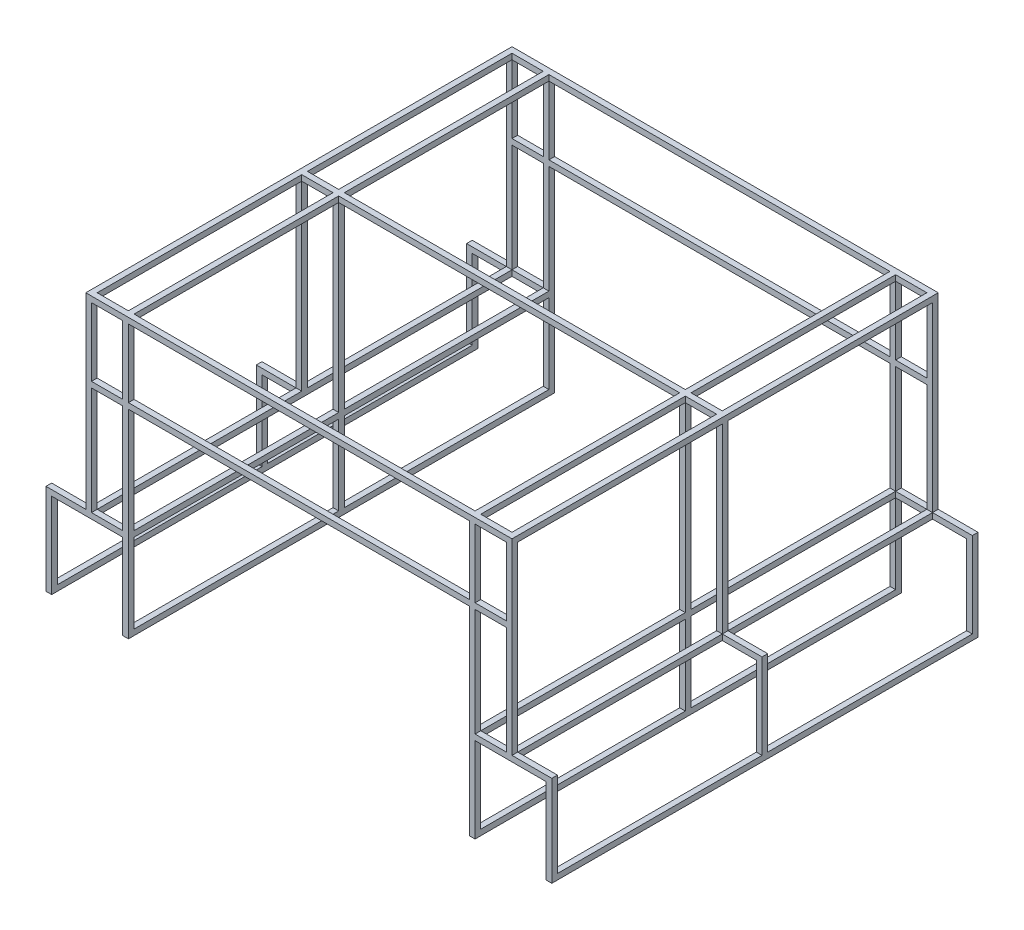
from build123d import *

# Parameters (mm, degrees)
SKETCH1_W                = 150
SKETCH1_H                = 1500
SKETCH1_W_2              = 110
SKETCH1_H_2              = 1460
BOSS_EXTRUDE1_DEPTH      = 20
SKETCH2_W                = 20
SKETCH2_H                = 20
BOSS_EXTRUDE2_DEPTH      = 640
SKETCH3_W                = 150
SKETCH3_H                = 1500
SKETCH3_W_2              = 110
SKETCH3_H_2              = 1460
BOSS_EXTRUDE3_DEPTH      = 20
SKETCH4_W                = 20
SKETCH4_H                = 20
BOSS_EXTRUDE4_DEPTH      = 660
SKETCH5_W                = 20
SKETCH5_H                = 20
BOSS_EXTRUDE5_DEPTH      = 600
BOSS_EXTRUDE5_DEPTH_BACK = 130
SKETCH6_W                = 140
SKETCH6_H                = 20
BOSS_EXTRUDE6_DEPTH      = 20
SKETCH7_W                = 20
SKETCH7_H                = 20
BOSS_EXTRUDE7_DEPTH      = 300
BOSS_EXTRUDE8_START      = -1480
SKETCH8_W                = 20
SKETCH8_H                = 20
BOSS_EXTRUDE8_DEPTH      = 1460


with BuildPart() as part:
    # Sketch1 → Boss-Extrude1 (new body)
    with BuildSketch(Plane(origin=(0, 0, 0), x_dir=(1, 0, 0), z_dir=(0, 1, 0))):
        with Locations((675, 0)):
            Rectangle(SKETCH1_W, SKETCH1_H)
        with Locations((675, 0)):
            Rectangle(SKETCH1_W_2, SKETCH1_H_2, mode=Mode.SUBTRACT)
    extrude(amount=BOSS_EXTRUDE1_DEPTH)

    # Sketch2 → Boss-Extrude2 (add)
    with BuildSketch(Plane(origin=(0, 20, 0), x_dir=(1, 0, 0), z_dir=(0, 1, 0))):
        with Locations((610, 740)):
            Rectangle(SKETCH2_W, SKETCH2_H)
        with Locations((740, 740)):
            Rectangle(SKETCH2_W, SKETCH2_H)
        with Locations((610, -740)):
            Rectangle(SKETCH2_W, SKETCH2_H)
        with Locations((740, -740)):
            Rectangle(SKETCH2_W, SKETCH2_H)
    extrude(amount=BOSS_EXTRUDE2_DEPTH)

    # Sketch3 → Boss-Extrude3 (add)
    with BuildSketch(Plane(origin=(0, 660, 0), x_dir=(1, 0, 0), z_dir=(0, 1, 0))):
        with Locations((675, 0)):
            Rectangle(SKETCH3_W, SKETCH3_H)
        with Locations((675, 0)):
            Rectangle(SKETCH3_W_2, SKETCH3_H_2, mode=Mode.SUBTRACT)
    extrude(amount=BOSS_EXTRUDE3_DEPTH)

    # Sketch4 → Boss-Extrude4 (add)
    with BuildSketch(Plane.XZ):
        with Locations((740, 0)):
            Rectangle(SKETCH4_W, SKETCH4_H)
        with Locations((610, 0)):
            Rectangle(SKETCH4_W, SKETCH4_H)
    extrude(amount=-BOSS_EXTRUDE4_DEPTH)

    # Sketch5 → Boss-Extrude5 (add, two sides)
    with BuildSketch(Plane.ZY.offset(-600)) as boss_extrude5_sk:
        with Locations((-740, 410)):
            Rectangle(SKETCH5_W, SKETCH5_H)
        with Locations((-740, 670)):
            Rectangle(SKETCH5_W, SKETCH5_H)
        with Locations((740, 410)):
            Rectangle(SKETCH5_W, SKETCH5_H)
        with Locations((740, 670)):
            Rectangle(SKETCH5_W, SKETCH5_H)
        with Locations((0, 670)):
            Rectangle(SKETCH5_W, SKETCH5_H)
    extrude(amount=BOSS_EXTRUDE5_DEPTH)
    extrude(boss_extrude5_sk.sketch, amount=-BOSS_EXTRUDE5_DEPTH_BACK)

    # Sketch6 → Boss-Extrude6 (add)
    with BuildSketch(Plane.XZ):
        with Locations((820, 740)):
            Rectangle(SKETCH6_W, SKETCH6_H)
        with Locations((820, 0)):
            Rectangle(SKETCH6_W, SKETCH6_H)
        with Locations((820, -740)):
            Rectangle(SKETCH6_W, SKETCH6_H)
    extrude(amount=-BOSS_EXTRUDE6_DEPTH)

    # Sketch7 → Boss-Extrude7 (add)
    with BuildSketch(Plane.XZ):
        with Locations((610, 740)):
            Rectangle(SKETCH7_W, SKETCH7_H)
        with Locations((880, 740)):
            Rectangle(SKETCH7_W, SKETCH7_H)
        with Locations((610, 0)):
            Rectangle(SKETCH7_W, SKETCH7_H)
        with Locations((610, -740)):
            Rectangle(SKETCH7_W, SKETCH7_H)
        with Locations((880, -740)):
            Rectangle(SKETCH7_W, SKETCH7_H)
        with Locations((880, 0)):
            Rectangle(SKETCH7_W, SKETCH7_H)
    extrude(amount=BOSS_EXTRUDE7_DEPTH)

    # Sketch8 → Boss-Extrude8 (add)
    with BuildSketch(Plane.XY.offset(750).offset(BOSS_EXTRUDE8_START)):
        with Locations((610, -290)):
            Rectangle(SKETCH8_W, SKETCH8_H)
        with Locations((880, -290)):
            Rectangle(SKETCH8_W, SKETCH8_H)
    extrude(amount=BOSS_EXTRUDE8_DEPTH)

    # Mirror1: part across plane


with BuildPart() as part_1:
    add(part.part)
    add(part.part.mirror(Plane(origin=(0, 0, 0), x_dir=(0, 0, 1), z_dir=(1, 0, 0))))


solid = part_1.part
